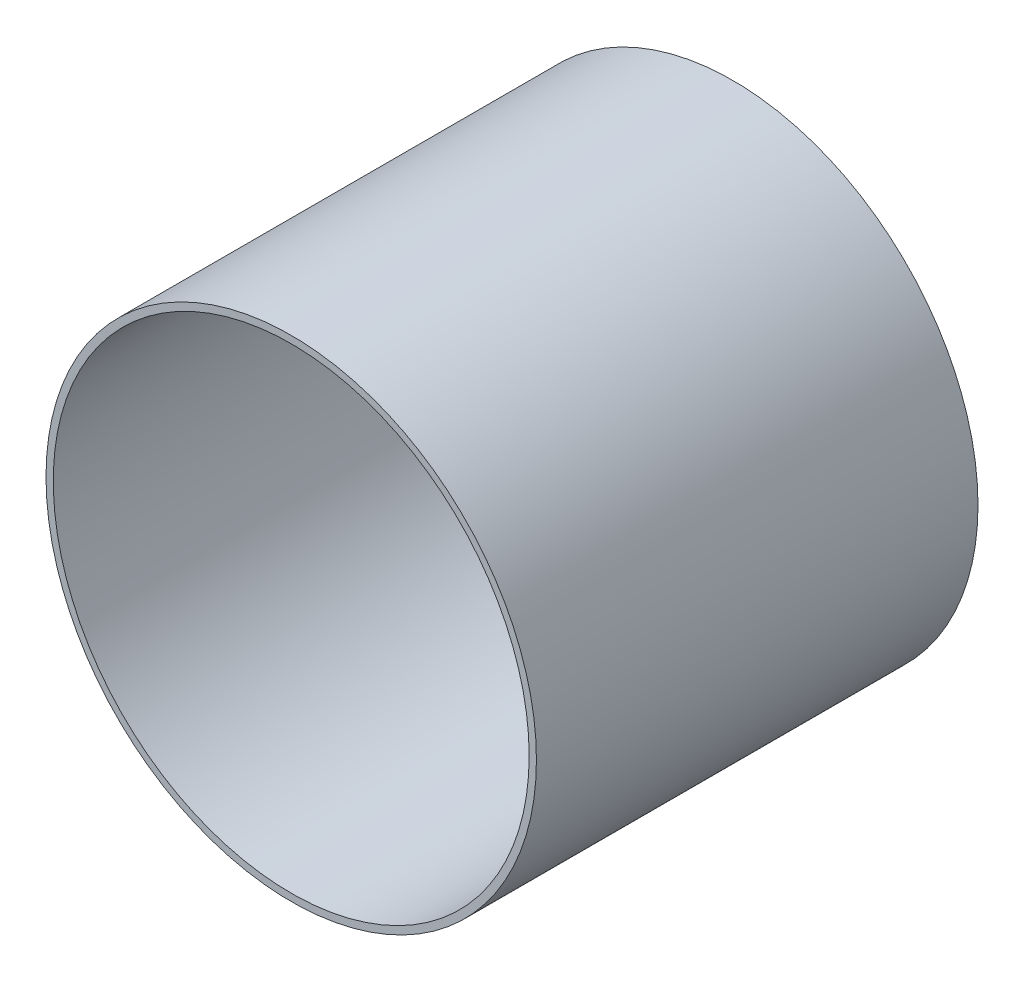
from build123d import *

# Parameters (mm, degrees)
SKETCH1_R           = 63.4746
SKETCH1_R_2         = 61.595
BOSS_EXTRUDE1_DEPTH = 57.15


with BuildPart() as part:
    # Sketch1 → Boss-Extrude1 (new body, symmetric)
    with BuildSketch(Plane.XY):
        Circle(SKETCH1_R)
        Circle(SKETCH1_R_2, mode=Mode.SUBTRACT)
    extrude(amount=BOSS_EXTRUDE1_DEPTH, both=True)


solid = part.part
